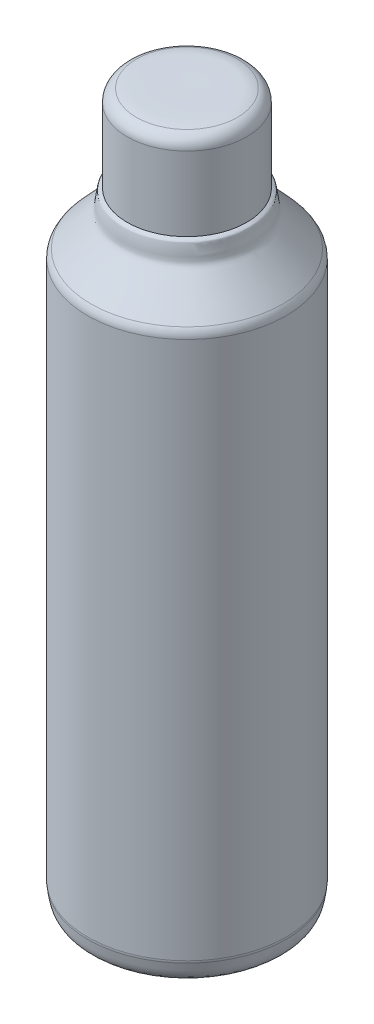
from build123d import *


with BuildPart() as part:
    # Sketch1 → Revolve1 (revolve)
    with BuildSketch(Plane.XY):
        with BuildLine():
            Line((299.869822457, 19.969981452), (299.869822457, 581.9306305))
            add(Edge.make_bspline(
                [(260.243694036, 580.74911208), (263.082956961, 581.563236016), (266.059385675, 581.972800203), (269, 582.009104084), (279.289376505, 582.136133423), (289.579854883, 582.084453334), (299.869822457, 581.9306305)],
                knots=[1.210890247, 1.210890247, 1.210890247, 1.210890247, 2, 2, 2, 2.440961889, 2.440961889, 2.440961889, 2.440961889], degree=3))
            ThreePointArc((260.243694036, 580.74911208), (255.013666059, 577.154654049), (253, 571.136475738))
            Line((253, 571.136475738), (253, 513))
            add(Edge.make_bspline(
                [(224.604387653, 471.772395411), (231.364357938, 479.199956822), (238.40494302, 486.462792022), (245, 494), (246.09750768, 495.254294491), (247.381015539, 496.452538849), (248, 498), (248.753027097, 499.882567742), (248.575161437, 502.017420038), (249, 504), (250.83185132, 512.548639496), (248.636070132, 510.818035066), (253, 513)],
                knots=[1.073552287, 1.073552287, 1.073552287, 1.073552287, 2, 2, 2, 3, 3, 3, 4, 4, 4, 5, 5, 5, 5], degree=3))
            ThreePointArc((224.604387653, 471.772395411), (222.673797036, 468.650094884), (222, 465.041502601))
            Line((222, 465.041502601), (222, 42.919041115))
            ThreePointArc((222, 42.919041115), (222.037005327, 42.059542919), (222.14774743, 41.206405924))
            add(Edge.make_bspline(
                [(227.708226393, 27.19266873), (223.001482513, 30.417198271), (223.012565993, 36.231376239), (222.14774743, 41.206405924)],
                knots=[8.018855033, 8.018855033, 8.018855033, 8.018855033, 8.950003244, 8.950003244, 8.950003244, 8.950003244], degree=3))
            add(Edge.make_bspline(
                [(299.869822457, 19.969981452), (245.269197516, 19.906383893), (227.708226393, 27.19266873)],
                knots=[0, 0, 0, 0.455690214, 0.455690214, 0.455690214], degree=2))
        make_face()
    revolve(axis=Axis((299.869822457, 19.969981452, 0), (0, 1, 0)))


solid = part.part
